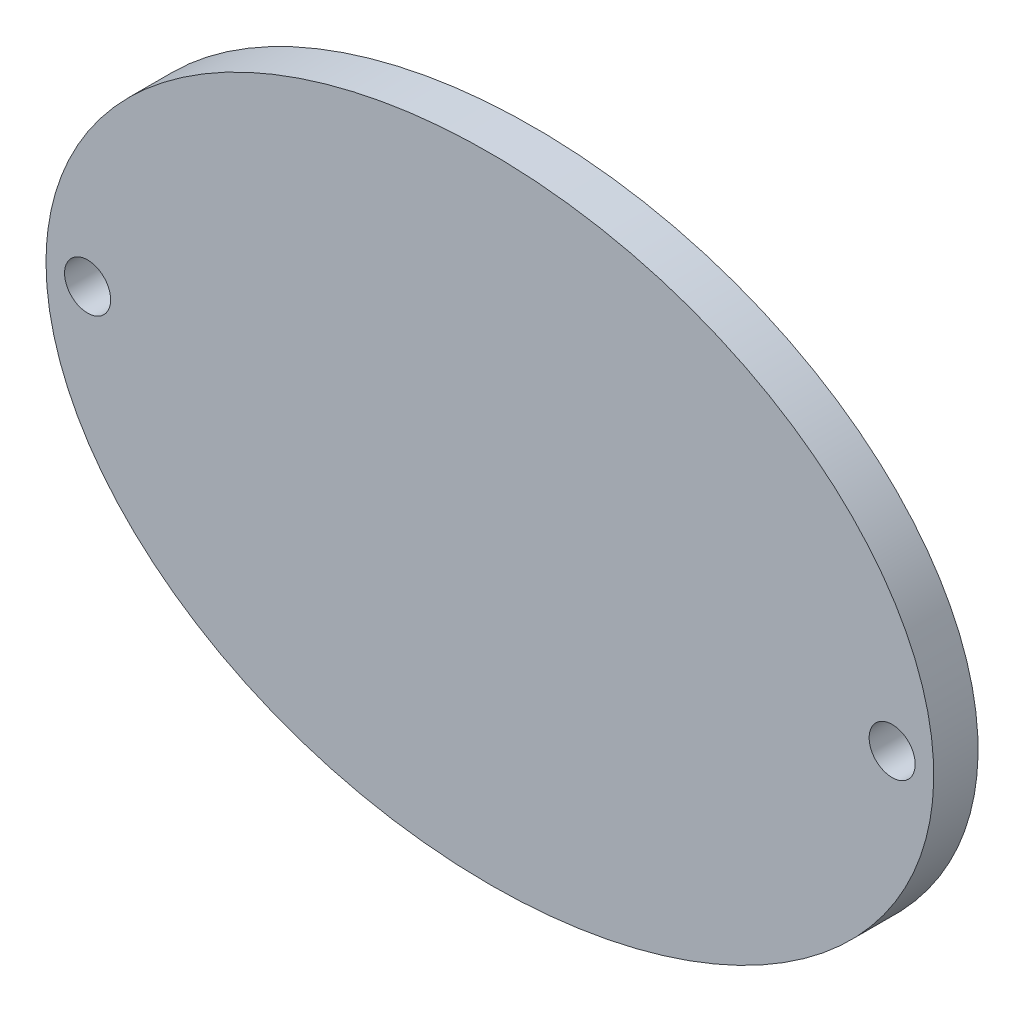
from build123d import *

# Parameters (mm, degrees)
SKETCH1_RX          = 31.8
SKETCH1_RY          = 22.7
BOSS_EXTRUDE1_DEPTH = 3.175
SKETCH2_R           = 1.65
CUT_EXTRUDE1_DEPTH  = 3.175


with BuildPart() as part:
    # Sketch1 → Boss-Extrude1 (new body)
    with BuildSketch(Plane.XY):
        with Locations(Location((0, 0), (0, 0, 180))):
            Ellipse(SKETCH1_RX, SKETCH1_RY)
    extrude(amount=BOSS_EXTRUDE1_DEPTH)

    # Sketch2 → Cut-Extrude1 (cut)
    with BuildSketch(Plane(origin=(0, 0, 0), x_dir=(-1, 0, 0), z_dir=(0, 0, -1))):
        with Locations((-28.82, 0)):
            Circle(SKETCH2_R)
        with Locations((28.82, 0)):
            Circle(SKETCH2_R)
    extrude(amount=-CUT_EXTRUDE1_DEPTH, mode=Mode.SUBTRACT)


solid = part.part
